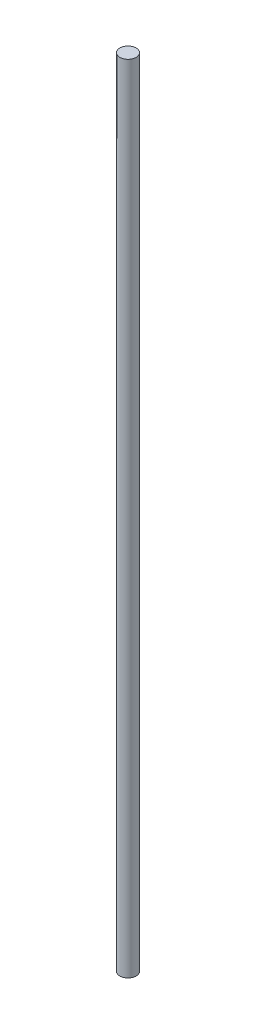
from build123d import *

# Parameters (mm, degrees)
SKETCH1_W = 4
SKETCH1_H = 390


with BuildPart() as part:
    # Sketch1 → Revolve1 (revolve)
    with BuildSketch(Plane.XY):
        with Locations((2, 0)):
            Rectangle(SKETCH1_W, SKETCH1_H)
    revolve(axis=Axis((0, 195, 0), (0, -1, 0)))


solid = part.part
